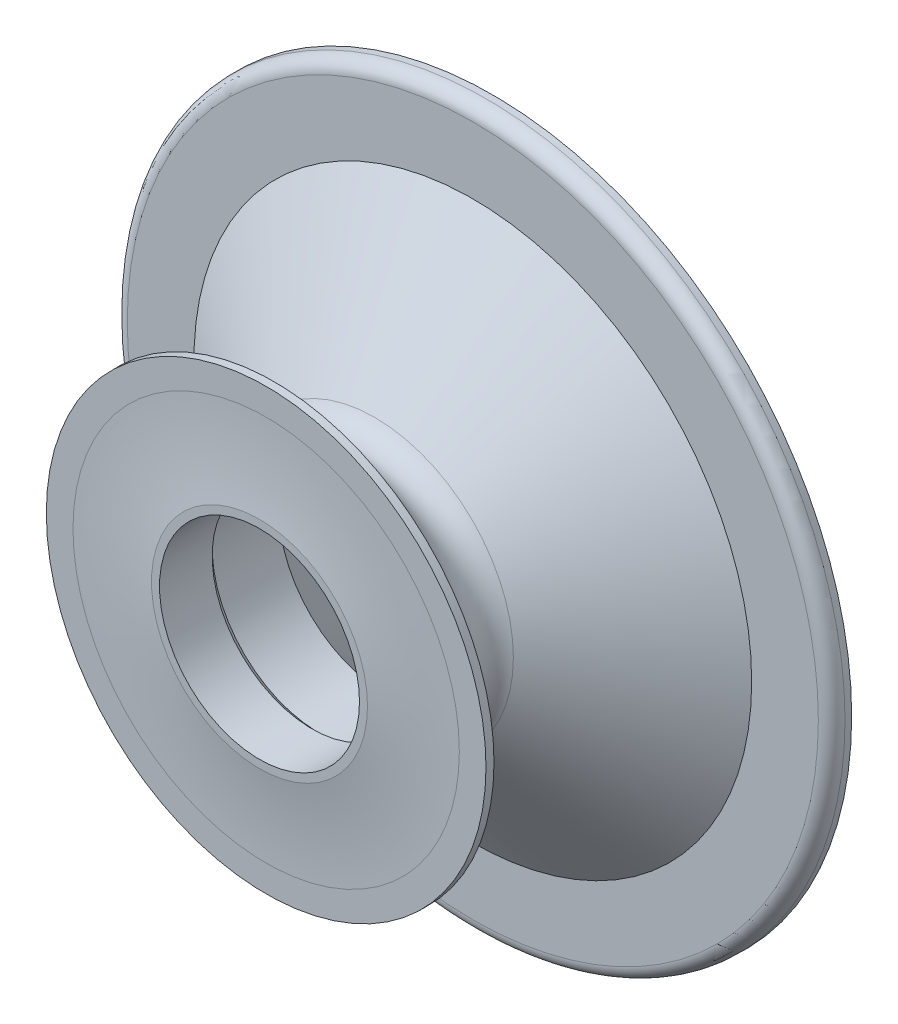
from build123d import *

# Parameters (mm, degrees)
FILLET1_R = 1


with BuildPart() as part:
    # Sketch1 → Revolve1 (revolve)
    with BuildSketch(Plane(origin=(0, 0, 0), x_dir=(0, 0, -1), z_dir=(1, 0, 0))):
        with BuildLine():
            Line((-2.5, 8.05), (2.5, 8.05))
            Line((2.5, 8.05), (10.5, 16.05))
            Line((10.5, 16.05), (10.5, 26.916438469))
            Line((10.5, 26.916438469), (9, 26.916438469))
            Line((9, 26.916438469), (9, 20.916438469))
            Line((9, 20.916438469), (1.638304089, 10.402847127))
            ThreePointArc((1.638304089, 10.402847127), (0, 9.55), (-1.638304089, 10.402847127))
            Line((-1.638304089, 10.402847127), (-5.9, 16.489179649))
            Line((-5.9, 16.489179649), (-6.5, 16.489179649))
            Line((-6.5, 16.489179649), (-6.5, 14.489179649))
            ThreePointArc((-6.5, 14.489179649), (-6.625190798, 11.284822592), (-7, 8.1))
            Line((-7, 8.1), (-7, 7.5))
            Line((-7, 7.5), (-3.05, 7.5))
            Line((-3.05, 7.5), (-2.5, 8.05))
        make_face()
    revolve(axis=Axis((0, 0, 162.721569491), (0, 0, -1)))

    # Fillet1
    fillet1_edges = [part.edges().sort_by_distance(p)[0] for p in [
        (0, -26.916438469, -9),
    ]]
    fillet(fillet1_edges, radius=FILLET1_R)


solid = part.part
